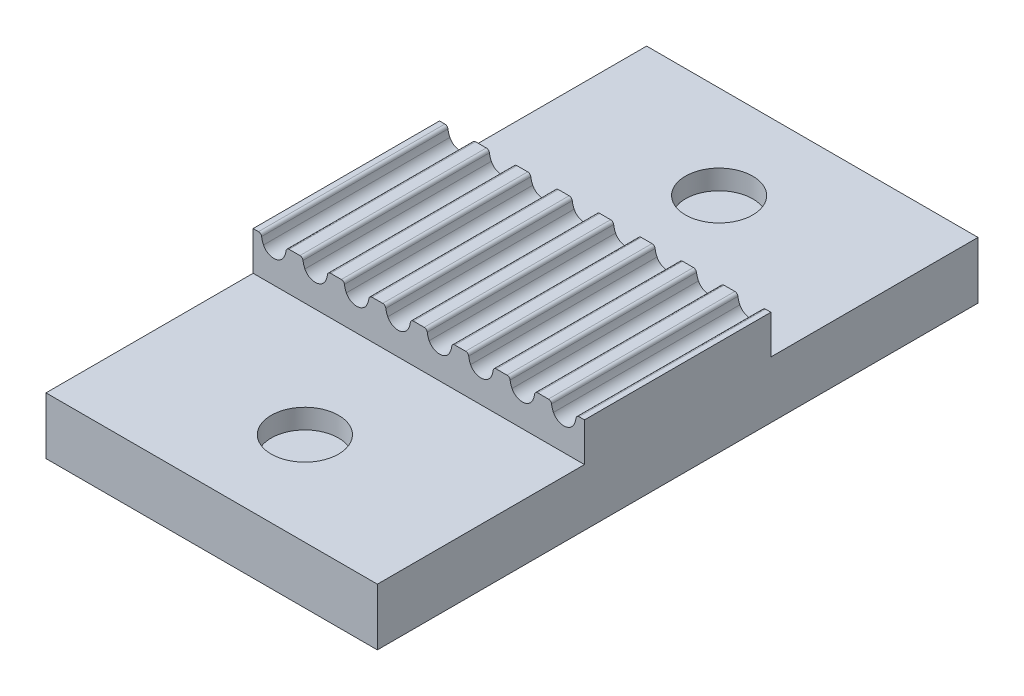
from build123d import *

# Parameters (mm, degrees)
BOSS_EXTRUDE1_DEPTH  = 9
SKETCH6_W            = 16
SKETCH6_H            = 9
BOSS_EXTRUDE6_DEPTH  = 2.75
SKETCH7_W            = 16
SKETCH7_H            = 2.75
BOSS_EXTRUDE7_DEPTH  = 10
SKETCH8_W            = 16
SKETCH8_H            = 2.75
BOSS_EXTRUDE8_DEPTH  = 10
SKETCH10_R           = 1.625
CUT_EXTRUDE1_DEPTH   = 10
CUT_EXTRUDE2_DEPTH   = 1.5
BOSS_EXTRUDE11_DEPTH = 0.3


with BuildPart() as part:
    # Sketch1 → Boss-Extrude1 (new body)
    with BuildSketch(Plane.XY):
        with BuildLine():
            Line((16.338025278, 17.821295042), (16.597849853, 17.821295042))
            Line((16.597849853, 17.821295042), (16.597849853, 15.951295042))
            Line((16.597849853, 15.951295042), (0.597849853, 15.951295042))
            Line((0.597849853, 15.951295042), (0.597849853, 17.821295042))
            Line((0.597849853, 17.821295042), (0.857674428, 17.821295042))
            ThreePointArc((0.857674428, 17.821295042), (0.956581499, 17.784066453), (1.006392961, 17.690860259))
            ThreePointArc((1.006392961, 17.690860259), (1.040238138, 17.533232888), (1.098973448, 17.383092794))
            ThreePointArc((1.098973448, 17.383092794), (1.303700441, 17.155655983), (1.597849853, 17.071295042))
            ThreePointArc((1.597849853, 17.071295042), (1.891999264, 17.155655983), (2.096726257, 17.383092794))
            ThreePointArc((2.096726257, 17.383092794), (2.155461567, 17.533232888), (2.189306744, 17.690860259))
            ThreePointArc((2.189306744, 17.690860259), (2.239118207, 17.784066453), (2.338025278, 17.821295042))
            Line((2.338025278, 17.821295042), (2.857674428, 17.821295042))
            ThreePointArc((2.857674428, 17.821295042), (2.956581499, 17.784066453), (3.006392961, 17.690860259))
            ThreePointArc((3.006392961, 17.690860259), (3.040238138, 17.533232888), (3.098973448, 17.383092794))
            ThreePointArc((3.098973448, 17.383092794), (3.303700441, 17.155655983), (3.597849853, 17.071295042))
            ThreePointArc((3.597849853, 17.071295042), (3.891999264, 17.155655983), (4.096726257, 17.383092794))
            ThreePointArc((4.096726257, 17.383092794), (4.155461567, 17.533232888), (4.189306744, 17.690860259))
            ThreePointArc((4.189306744, 17.690860259), (4.239118207, 17.784066453), (4.338025278, 17.821295042))
            Line((4.338025278, 17.821295042), (4.857674428, 17.821295042))
            ThreePointArc((4.857674428, 17.821295042), (4.956581499, 17.784066453), (5.006392961, 17.690860259))
            ThreePointArc((5.006392961, 17.690860259), (5.040238138, 17.533232888), (5.098973448, 17.383092794))
            ThreePointArc((5.098973448, 17.383092794), (5.303700441, 17.155655983), (5.597849853, 17.071295042))
            ThreePointArc((5.597849853, 17.071295042), (5.891999264, 17.155655983), (6.096726257, 17.383092794))
            ThreePointArc((6.096726257, 17.383092794), (6.155461567, 17.533232888), (6.189306744, 17.690860259))
            ThreePointArc((6.189306744, 17.690860259), (6.239118207, 17.784066453), (6.338025278, 17.821295042))
            Line((6.338025278, 17.821295042), (6.857674428, 17.821295042))
            ThreePointArc((6.857674428, 17.821295042), (6.956581499, 17.784066453), (7.006392961, 17.690860259))
            ThreePointArc((7.006392961, 17.690860259), (7.040238138, 17.533232888), (7.098973448, 17.383092794))
            ThreePointArc((7.098973448, 17.383092794), (7.303700441, 17.155655983), (7.597849853, 17.071295042))
            ThreePointArc((7.597849853, 17.071295042), (7.891999264, 17.155655983), (8.096726257, 17.383092794))
            ThreePointArc((8.096726257, 17.383092794), (8.155461567, 17.533232888), (8.189306744, 17.690860259))
            ThreePointArc((8.189306744, 17.690860259), (8.239118207, 17.784066453), (8.338025278, 17.821295042))
            Line((8.338025278, 17.821295042), (8.857674428, 17.821295042))
            ThreePointArc((8.857674428, 17.821295042), (8.956581499, 17.784066453), (9.006392961, 17.690860259))
            ThreePointArc((9.006392961, 17.690860259), (9.040238138, 17.533232888), (9.098973448, 17.383092794))
            ThreePointArc((9.098973448, 17.383092794), (9.303700441, 17.155655983), (9.597849853, 17.071295042))
            ThreePointArc((9.597849853, 17.071295042), (9.891999264, 17.155655983), (10.096726257, 17.383092794))
            ThreePointArc((10.096726257, 17.383092794), (10.155461567, 17.533232888), (10.189306744, 17.690860259))
            ThreePointArc((10.189306744, 17.690860259), (10.239118207, 17.784066453), (10.338025278, 17.821295042))
            Line((10.338025278, 17.821295042), (10.857674428, 17.821295042))
            ThreePointArc((10.857674428, 17.821295042), (10.956581499, 17.784066453), (11.006392961, 17.690860259))
            ThreePointArc((11.006392961, 17.690860259), (11.040238138, 17.533232888), (11.098973448, 17.383092794))
            ThreePointArc((11.098973448, 17.383092794), (11.303700441, 17.155655983), (11.597849853, 17.071295042))
            ThreePointArc((11.597849853, 17.071295042), (11.891999264, 17.155655983), (12.096726257, 17.383092794))
            ThreePointArc((12.096726257, 17.383092794), (12.155461567, 17.533232888), (12.189306744, 17.690860259))
            ThreePointArc((12.189306744, 17.690860259), (12.239118207, 17.784066453), (12.338025278, 17.821295042))
            Line((12.338025278, 17.821295042), (12.857674428, 17.821295042))
            ThreePointArc((12.857674428, 17.821295042), (12.956581499, 17.784066453), (13.006392961, 17.690860259))
            ThreePointArc((13.006392961, 17.690860259), (13.040238138, 17.533232888), (13.098973448, 17.383092794))
            ThreePointArc((13.098973448, 17.383092794), (13.303700441, 17.155655983), (13.597849853, 17.071295042))
            ThreePointArc((13.597849853, 17.071295042), (13.891999264, 17.155655983), (14.096726257, 17.383092794))
            ThreePointArc((14.096726257, 17.383092794), (14.155461567, 17.533232888), (14.189306744, 17.690860259))
            ThreePointArc((14.189306744, 17.690860259), (14.239118207, 17.784066453), (14.338025278, 17.821295042))
            Line((14.338025278, 17.821295042), (14.857674428, 17.821295042))
            ThreePointArc((14.857674428, 17.821295042), (14.956581499, 17.784066453), (15.006392961, 17.690860259))
            ThreePointArc((15.006392961, 17.690860259), (15.040238138, 17.533232888), (15.098973448, 17.383092794))
            ThreePointArc((15.098973448, 17.383092794), (15.303700441, 17.155655983), (15.597849853, 17.071295042))
            ThreePointArc((15.597849853, 17.071295042), (15.891999264, 17.155655983), (16.096726257, 17.383092794))
            ThreePointArc((16.096726257, 17.383092794), (16.155461567, 17.533232888), (16.189306744, 17.690860259))
            ThreePointArc((16.189306744, 17.690860259), (16.239118207, 17.784066453), (16.338025278, 17.821295042))
        make_face()
    extrude(amount=BOSS_EXTRUDE1_DEPTH)

    # Sketch6 → Boss-Extrude6 (add)
    with BuildSketch(Plane.XZ.offset(-15.951295042)):
        with Locations((8.597849853, 4.5)):
            Rectangle(SKETCH6_W, SKETCH6_H)
    extrude(amount=BOSS_EXTRUDE6_DEPTH)

    # Sketch7 → Boss-Extrude7 (add)
    with BuildSketch(Plane(origin=(0, 0, 0), x_dir=(-1, 0, 0), z_dir=(0, 0, -1))):
        with Locations((-8.597849853, 14.576295042)):
            Rectangle(SKETCH7_W, SKETCH7_H)
    extrude(amount=BOSS_EXTRUDE7_DEPTH)

    # Sketch8 → Boss-Extrude8 (add)
    with BuildSketch(Plane.XY.offset(9)):
        with Locations((8.597849853, 14.576295042)):
            Rectangle(SKETCH8_W, SKETCH8_H)
    extrude(amount=BOSS_EXTRUDE8_DEPTH)

    # Sketch10 → Cut-Extrude1 (cut)
    with BuildSketch(Plane.XZ.offset(-13.201295042)):
        with Locations((8.597849853, 14.5)):
            Circle(SKETCH10_R)
        with Locations((8.597849853, -5.5)):
            Circle(SKETCH10_R)
    extrude(amount=-CUT_EXTRUDE1_DEPTH, mode=Mode.SUBTRACT)

    # Sketch11 → Cut-Extrude2 (cut)
    with BuildSketch(Plane.XZ.offset(-13.201295042)):
        Polygon((6.937967829, 11.625), (10.257731877, 11.625), (11.9176139, 14.5), (10.257731877, 17.375), (6.937967829, 17.375), (5.278085805, 14.5), align=None)
        Polygon((5.278085805, -5.5), (6.937967829, -2.625), (10.257731877, -2.625), (11.9176139, -5.5), (10.257731877, -8.375), (6.937967829, -8.375), align=None)
    extrude(amount=-CUT_EXTRUDE2_DEPTH, mode=Mode.SUBTRACT)

    # Sketch15 → Boss-Extrude11 (add)
    with BuildSketch(Plane.XZ.offset(-14.701295042)):
        Polygon((5.278085805, 14.5), (6.937967829, 11.625), (10.257731877, 11.625), (11.9176139, 14.5), (10.257731877, 17.375), (6.937967829, 17.375), align=None)
        Polygon((6.937967829, -8.375), (5.278085805, -5.5), (6.937967829, -2.625), (10.257731877, -2.625), (11.9176139, -5.5), (10.257731877, -8.375), align=None)
    extrude(amount=-BOSS_EXTRUDE11_DEPTH)


solid = part.part
